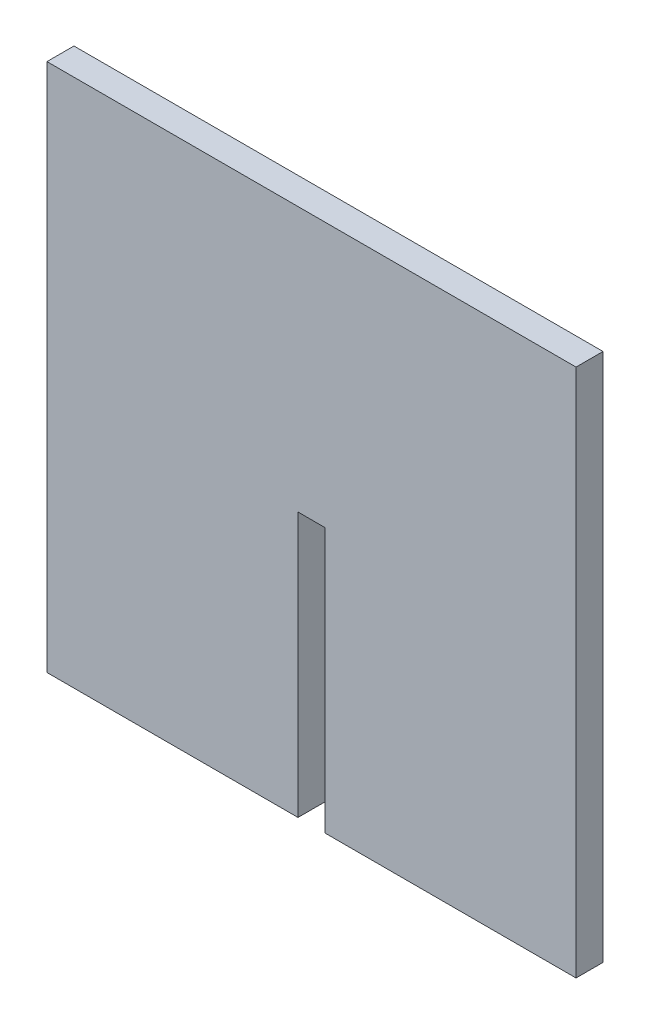
from build123d import *

# Parameters (mm, degrees)
BOSS_EXTRUDE1_DEPTH = 4.318


with BuildPart() as part:
    # Sketch1 → Boss-Extrude1 (new body)
    with BuildSketch(Plane.XY):
        Polygon((0, 0), (40.141, 0), (40.141, 42.3), (44.459, 42.3), (44.459, 0), (84.6, 0), (84.6, 84.6), (0, 84.6), align=None)
    extrude(amount=BOSS_EXTRUDE1_DEPTH)


solid = part.part
